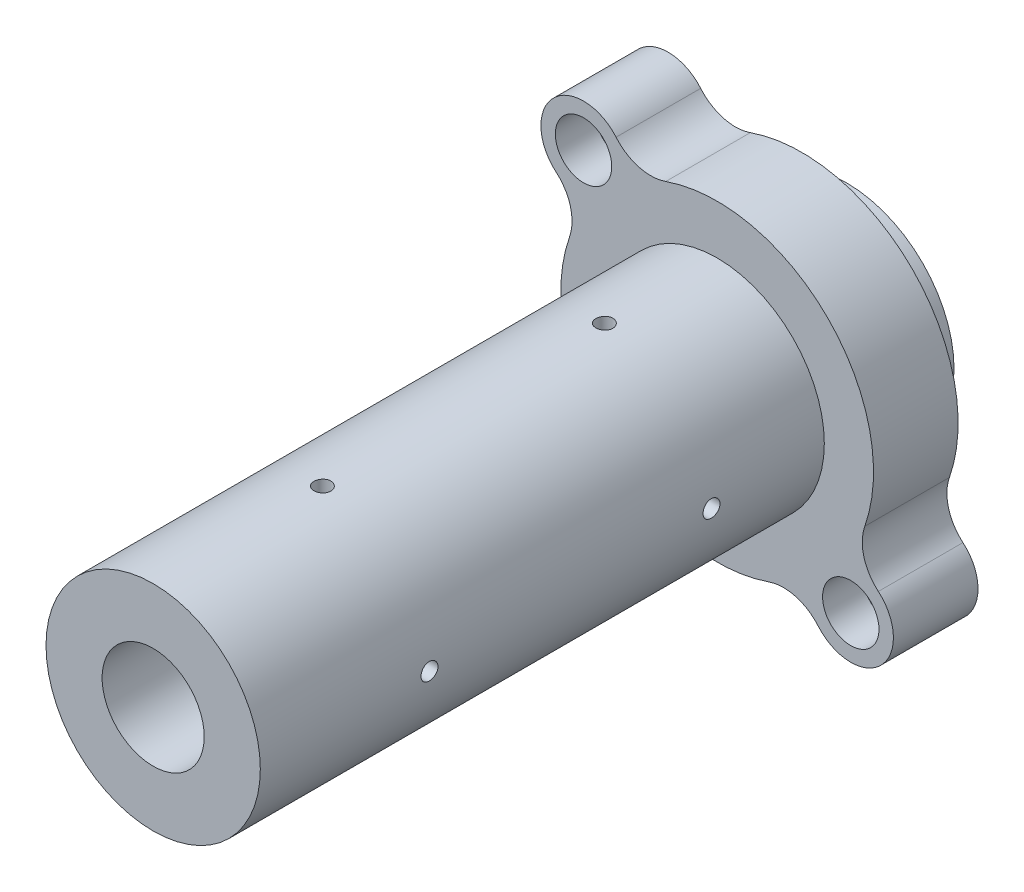
from build123d import *

# Parameters (mm, degrees)
ESQUISSE1_R                  = 2.55
BOSS_EXTRU_1_DEPTH           = 15
ESQUISSE9_R                  = 19
BOSS_EXTRU_4_DEPTH           = 100
BOSS_EXTRU_4_DEPTH_BACK      = 23
ESQUISSE12_R                 = 9.05
ENL_V_MAT_EXTRU_2_DEPTH      = 124
ESQUISSE13_R                 = 5
ENL_V_MAT_EXTRU_3_DEPTH      = 7
ESQUISSE14_R                 = 1.5
ENL_V_MAT_EXTRU_4_DEPTH      = 32.248101798
ENL_V_MAT_EXTRU_4_DEPTH_BACK = 32.248101798
ESQUISSE15_R                 = 1.5
ENL_V_MAT_EXTRU_5_DEPTH      = 32.248101798
ENL_V_MAT_EXTRU_5_DEPTH_BACK = 32.248101798


with BuildPart() as part:
    # Esquisse1 → Boss.-Extru.1 (new body)
    with BuildSketch(Plane.XY.offset(838.2)):
        with BuildLine():
            ThreePointArc((-9.11861011, 26.177363431), (-13.892343586, 26.012514183), (-17.921893066, 28.577360682))
            ThreePointArc((-17.921893066, 28.577360682), (-29.033821851, 29.033821851), (-28.577360682, 17.921893066))
            ThreePointArc((-28.577360682, 17.921893066), (-26.012514183, 13.892343586), (-26.177363431, 9.11861011))
            ThreePointArc((-26.177363431, 9.11861011), (-19.60106383, -19.60106383), (9.11861011, -26.177363431))
            ThreePointArc((9.11861011, -26.177363431), (13.892343586, -26.012514183), (17.921893066, -28.577360682))
            ThreePointArc((17.921893066, -28.577360682), (29.033821851, -29.033821851), (28.577360682, -17.921893066))
            ThreePointArc((28.577360682, -17.921893066), (26.012514183, -13.892343586), (26.177363431, -9.11861011))
            ThreePointArc((26.177363431, -9.11861011), (19.60106383, 19.60106383), (-9.11861011, 26.177363431))
        make_face()
        with Locations((23.68807717, -23.68807717)):
            Circle(ESQUISSE1_R, mode=Mode.SUBTRACT)
        with Locations((-23.68807717, 23.68807717)):
            Circle(ESQUISSE1_R, mode=Mode.SUBTRACT)
    extrude(amount=-BOSS_EXTRU_1_DEPTH)

    # Esquisse9 → Boss.-Extru.4 (add, two sides)
    with BuildSketch(Plane.XY.offset(838.2)) as boss_extru_4_sk:
        Circle(ESQUISSE9_R)
    extrude(amount=BOSS_EXTRU_4_DEPTH)
    extrude(boss_extru_4_sk.sketch, amount=-BOSS_EXTRU_4_DEPTH_BACK)

    # Esquisse12 → Enlèv. mat.-Extru.2 (cut, through all)
    with BuildSketch(Plane.XY.offset(938.2)):
        Circle(ESQUISSE12_R)
    extrude(amount=-ENL_V_MAT_EXTRU_2_DEPTH, mode=Mode.SUBTRACT)

    # Esquisse13 → Enlèv. mat.-Extru.3 (cut)
    with BuildSketch(Plane.XY.offset(838.2)):
        with Locations((-23.68807717, 23.68807717)):
            Circle(ESQUISSE13_R)
        with Locations((23.68807717, -23.68807717)):
            Circle(ESQUISSE13_R)
    extrude(amount=-ENL_V_MAT_EXTRU_3_DEPTH, mode=Mode.SUBTRACT)

    # Esquisse14 → Enlèv. mat.-Extru.4 (cut, two sides)
    with BuildSketch(Plane(origin=(0, 0, 0), x_dir=(1, 0, 0), z_dir=(0, 1, 0))) as enl_v_mat_extru_4_sk:
        with Locations((0, -858.2)):
            Circle(ESQUISSE14_R)
        with Locations((0, -908.2)):
            Circle(ESQUISSE14_R)
    extrude(amount=ENL_V_MAT_EXTRU_4_DEPTH, mode=Mode.SUBTRACT)
    extrude(enl_v_mat_extru_4_sk.sketch, amount=-ENL_V_MAT_EXTRU_4_DEPTH_BACK, mode=Mode.SUBTRACT)

    # Esquisse15 → Enlèv. mat.-Extru.5 (cut, two sides)
    with BuildSketch(Plane(origin=(0, 0, 0), x_dir=(0, 0, -1), z_dir=(1, 0, 0))) as enl_v_mat_extru_5_sk:
        with Locations((-858.2, 0)):
            Circle(ESQUISSE15_R)
        with Locations((-908.2, 0)):
            Circle(ESQUISSE15_R)
    extrude(amount=ENL_V_MAT_EXTRU_5_DEPTH, mode=Mode.SUBTRACT)
    extrude(enl_v_mat_extru_5_sk.sketch, amount=-ENL_V_MAT_EXTRU_5_DEPTH_BACK, mode=Mode.SUBTRACT)


solid = part.part
